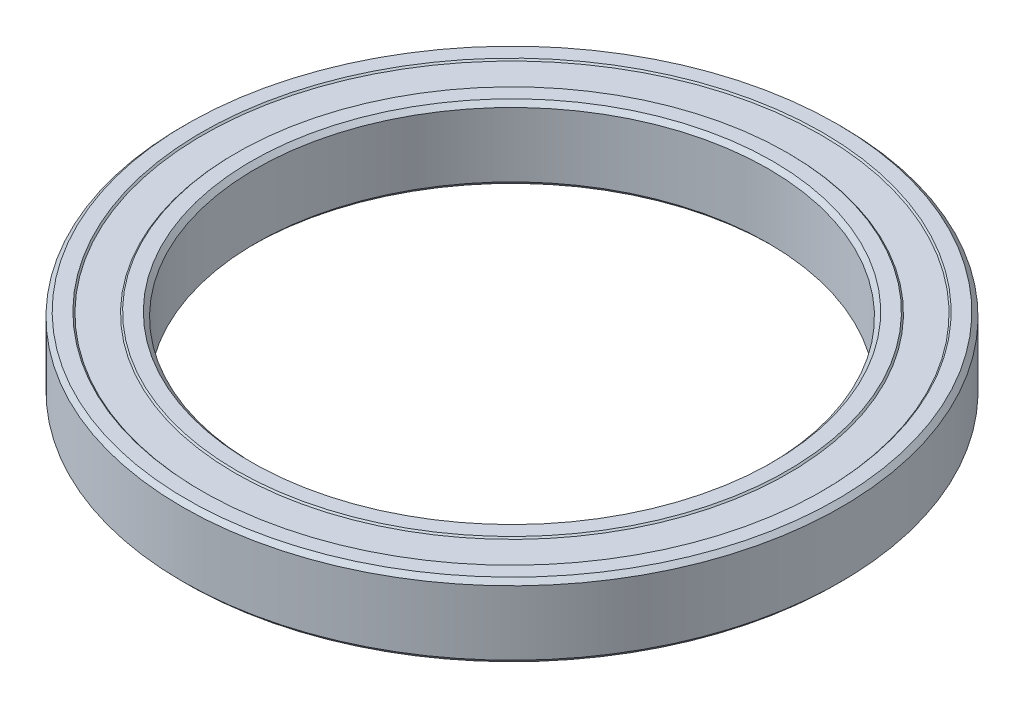
from build123d import *


with BuildPart() as part:
    # Sketch1 → Revolve1 (revolve)
    with BuildSketch(Plane.XY):
        Polygon((35, 4.4), (35, -4.4), (35.6, -5), (37.6, -5), (37.8, -4.8), (42.2, -4.8), (42.4, -5), (44.4, -5), (45, -4.4), (45, 4.4), (44.4, 5), (42.4, 5), (42.2, 4.8), (37.8, 4.8), (37.6, 5), (35.6, 5), align=None)
    revolve(axis=Axis((0, -1.349421972, 0), (0, 1, 0)))


solid = part.part
